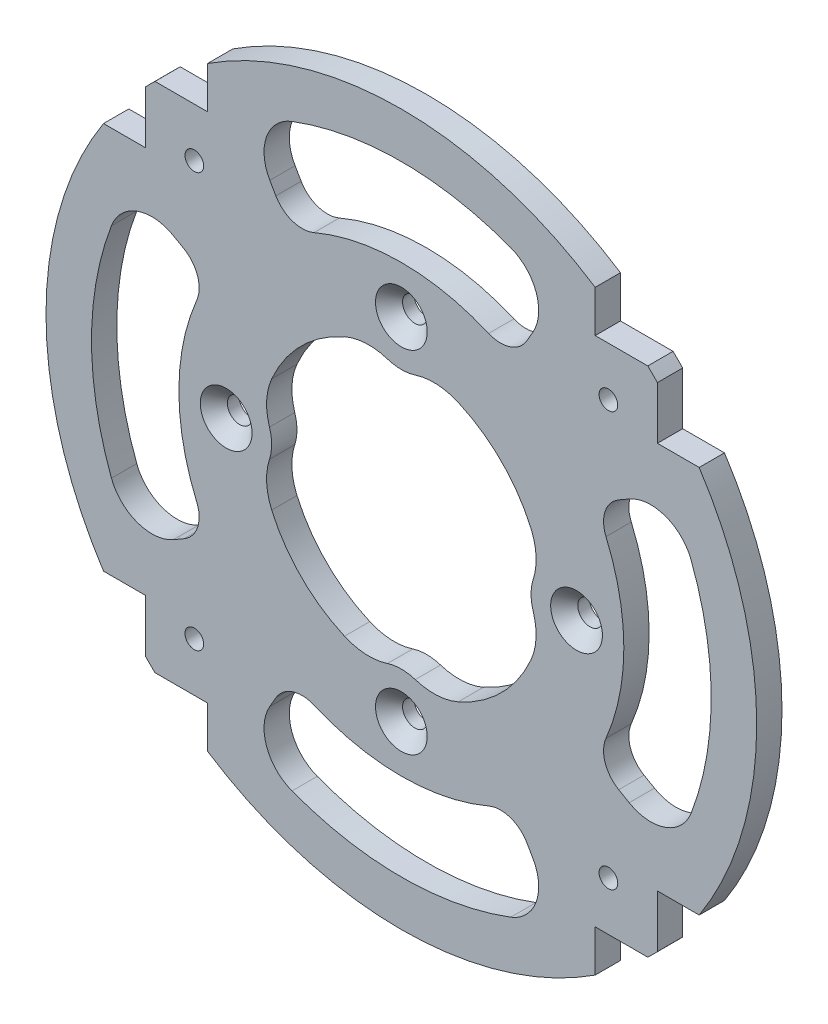
from build123d import *

# Parameters (mm, degrees)
SKETCH1_R           = 1.175
SKETCH1_R_2         = 1.55
BOSS_EXTRUDE1_DEPTH = 3.175
CUT_EXTRUDE2_DEPTH  = 64.189096172
CUT_EXTRUDE1_DEPTH  = 64.189096172
CIRPATTERN1_COUNT   = 4
CHAMFER1_SIZE       = 1.7


with BuildPart() as part:
    # Sketch1 → Boss-Extrude1 (new body)
    with BuildSketch(Plane.XY):
        with BuildLine():
            ThreePointArc((-28.274738921, -34.524335822), (-25.595848472, -36.554659976), (-22.771733351, -38.377581805))
            ThreePointArc((-22.771733351, -38.377581805), (-1.930585195, -44.583219554), (19.368987874, -40.202399602))
            ThreePointArc((19.368987874, -40.202399602), (22.3125, -38.646383644), (25.131805412, -36.875235345))
            ThreePointArc((25.131805412, -36.875235345), (42.197997698, -14.516184597), (42.498870951, 13.610165056))
            ThreePointArc((42.498870951, 13.610165056), (41.827558264, 15.551398481), (41.067627867, 17.459684027))
            ThreePointArc((41.067627867, 17.459684027), (25.603337609, 36.549414883), (2.379040875, 44.561539353))
            ThreePointArc((2.379040875, 44.561539353), (0, 44.625), (-2.379040875, 44.561539353))
            ThreePointArc((-2.379040875, 44.561539353), (-42.409403049, 13.886437917), (-28.274738921, -34.524335822))
        make_face()
        with Locations((-26, -26)):
            Circle(SKETCH1_R, mode=Mode.SUBTRACT)
        with Locations((0, -22)):
            Circle(SKETCH1_R_2, mode=Mode.SUBTRACT)
        with Locations((-22, 0)):
            Circle(SKETCH1_R_2, mode=Mode.SUBTRACT)
        with BuildLine():
            ThreePointArc((-7.14068763, 16.283088778), (-4.469980501, 16.914656425), (-1.748739828, 16.559123782))
            ThreePointArc((-1.748739828, 16.559123782), (0, 16.285), (1.748739828, 16.559123782))
            ThreePointArc((1.748739828, 16.559123782), (4.469980501, 16.914656425), (7.14068763, 16.283088778))
            ThreePointArc((7.14068763, 16.283088778), (12.572358569, 12.572358569), (16.283088778, 7.14068763))
            ThreePointArc((16.283088778, 7.14068763), (16.914656425, 4.469980501), (16.559123782, 1.748739828))
            ThreePointArc((16.559123782, 1.748739828), (16.285, 0), (16.559123782, -1.748739828))
            ThreePointArc((16.559123782, -1.748739828), (16.914656425, -4.469980501), (16.283088778, -7.14068763))
            ThreePointArc((16.283088778, -7.14068763), (12.572358569, -12.572358569), (7.14068763, -16.283088778))
            ThreePointArc((7.14068763, -16.283088778), (4.469980501, -16.914656425), (1.748739828, -16.559123782))
            ThreePointArc((1.748739828, -16.559123782), (0, -16.285), (-1.748739828, -16.559123782))
            ThreePointArc((-1.748739828, -16.559123782), (-4.469980501, -16.914656425), (-7.14068763, -16.283088778))
            ThreePointArc((-7.14068763, -16.283088778), (-12.572358569, -12.572358569), (-16.283088778, -7.14068763))
            ThreePointArc((-16.283088778, -7.14068763), (-16.914656425, -4.469980501), (-16.559123782, -1.748739828))
            ThreePointArc((-16.559123782, -1.748739828), (-16.285, 0), (-16.559123782, 1.748739828))
            ThreePointArc((-16.559123782, 1.748739828), (-16.914656425, 4.469980501), (-16.283088778, 7.14068763))
            ThreePointArc((-16.283088778, 7.14068763), (-12.572358569, 12.572358569), (-7.14068763, 16.283088778))
        make_face(mode=Mode.SUBTRACT)
        with Locations((26, -26)):
            Circle(SKETCH1_R, mode=Mode.SUBTRACT)
        with Locations((22, 0)):
            Circle(SKETCH1_R_2, mode=Mode.SUBTRACT)
        with Locations((0, 22)):
            Circle(SKETCH1_R_2, mode=Mode.SUBTRACT)
        with Locations((-26, 26)):
            Circle(SKETCH1_R, mode=Mode.SUBTRACT)
        with Locations((26, 26)):
            Circle(SKETCH1_R, mode=Mode.SUBTRACT)
    extrude(amount=BOSS_EXTRUDE1_DEPTH)

    # Sketch3 → Cut-Extrude2 (cut, through all)
    with BuildSketch(Plane.XY.offset(3.175)):
        Polygon((-36.863511092, 36.863511092), (-54.798863679, 36.863511092), (-54.798863679, 24.341335398), (-32.152970188, 24.341335398), (-32.152970188, 32.152970188), (-36.863511092, 32.152970188), align=None)
        Polygon((-36.863511092, 54.798863679), (-36.863511092, 36.863511092), (-32.152970188, 36.863511092), (-32.152970188, 32.152970188), (-24.341335398, 32.152970188), (-24.341335398, 54.798863679), align=None)
        Polygon((-32.152970188, -32.152970188), (-32.152970188, -24.341335398), (-54.798863679, -24.341335398), (-54.798863679, -36.863511092), (-36.863511092, -36.863511092), (-36.863511092, -54.798863679), (-24.341335398, -54.798863679), (-24.341335398, -32.152970188), align=None)
        Polygon((24.341335398, 32.152970188), (32.152970188, 32.152970188), (32.152970188, 36.863511092), (36.863511092, 36.863511092), (36.863511092, 54.798863679), (24.341335398, 54.798863679), align=None)
        Polygon((36.863511092, 32.152970188), (32.152970188, 32.152970188), (32.152970188, 24.341335398), (54.798863679, 24.341335398), (54.798863679, 36.863511092), (36.863511092, 36.863511092), align=None)
        Polygon((32.152970188, -32.152970188), (24.341335398, -32.152970188), (24.341335398, -54.798863679), (36.863511092, -54.798863679), (36.863511092, -36.863511092), (32.152970188, -36.863511092), align=None)
        Polygon((32.152970188, -32.152970188), (36.863511092, -32.152970188), (36.863511092, -36.863511092), (54.798863679, -36.863511092), (54.798863679, -24.341335398), (32.152970188, -24.341335398), align=None)
    extrude(amount=-CUT_EXTRUDE2_DEPTH, mode=Mode.SUBTRACT)

    # Sketch2 → Cut-Extrude1 (cut, through all)
    with BuildSketch(Plane.XY.offset(3.175)):
        with BuildLine():
            Line((-16.518713095, 28.611250357), (-15.76028553, 27.29761528))
            ThreePointArc((-15.76028553, 27.29761528), (-13.666256903, 25.588365448), (-10.965441293, 25.698301447))
            ThreePointArc((-10.965441293, 25.698301447), (0, 27.94), (10.965441293, 25.698301447))
            ThreePointArc((10.965441293, 25.698301447), (13.666256903, 25.588365448), (15.76028553, 27.29761528))
            Line((15.76028553, 27.29761528), (16.518713095, 28.611250357))
            ThreePointArc((16.518713095, 28.611250357), (16.929410685, 33.153177065), (13.732973771, 36.405954615))
            ThreePointArc((13.732973771, 36.405954615), (0, 38.91), (-13.732973771, 36.405954615))
            ThreePointArc((-13.732973771, 36.405954615), (-16.929410685, 33.153177065), (-16.518713095, 28.611250357))
        make_face()
    cut_extrude1 = extrude(amount=-CUT_EXTRUDE1_DEPTH, mode=Mode.SUBTRACT)

    # CirPattern1: Cut-Extrude1 ×4 about axis
    cirpattern1_axis = Axis((0, 0, 3.175), (0, 0, -1))
    for i in range(1, CIRPATTERN1_COUNT):
        add(cut_extrude1.rotate(cirpattern1_axis, i * 360 / CIRPATTERN1_COUNT), mode=Mode.SUBTRACT)

    # Chamfer1
    chamfer1_edges = [part.edges().sort_by_distance(p)[0] for p in [
        (-23.55, 0, 3.175),
        (-1.55, -22, 3.175),
        (20.45, 0, 3.175),
        (-1.55, 22, 3.175),
    ]]
    chamfer(chamfer1_edges, length=CHAMFER1_SIZE)


solid = part.part
